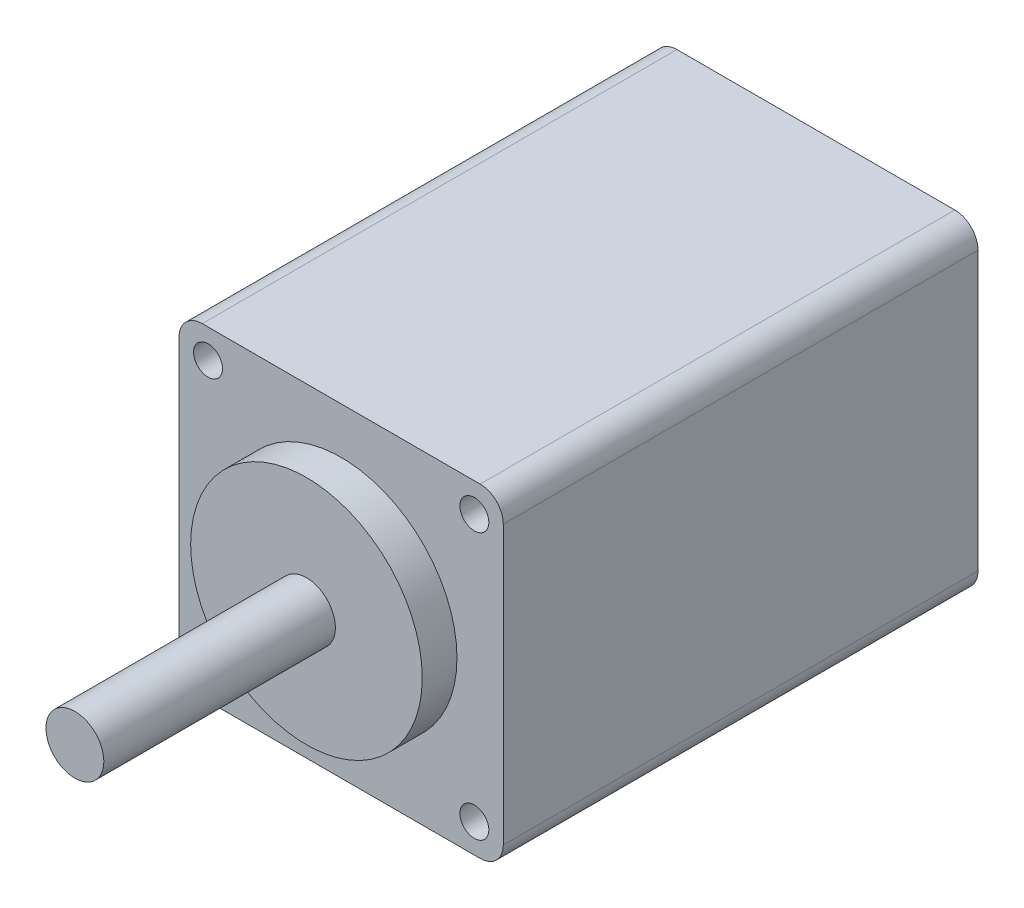
from build123d import *

# Parameters (mm, degrees)
SKETCH_1_W      = 28
SKETCH_1_H      = 28
SKETCH_1_R      = 1.25
EXTRUDE_1_DEPTH = 41
SKETCH_2_R      = 10
EXTRUDE_2_DEPTH = 3
SKETCH_3_R      = 2.5
EXTRUDE_3_DEPTH = 20
FILLET_1_R      = 2


with BuildPart() as part:
    # 草图1 → 凸台-拉伸1 (new body)
    with BuildSketch(Plane.XY):
        Rectangle(SKETCH_1_W, SKETCH_1_H)
        with Locations((-11.5, 11.5)):
            Circle(SKETCH_1_R, mode=Mode.SUBTRACT)
        with Locations((11.5, 11.5)):
            Circle(SKETCH_1_R, mode=Mode.SUBTRACT)
        with Locations((11.5, -11.5)):
            Circle(SKETCH_1_R, mode=Mode.SUBTRACT)
        with Locations((-11.5, -11.5)):
            Circle(SKETCH_1_R, mode=Mode.SUBTRACT)
    extrude(amount=EXTRUDE_1_DEPTH)

    # 草图2 → 凸台-拉伸2 (add)
    with BuildSketch(Plane.XY.offset(41)):
        Circle(SKETCH_2_R)
    extrude(amount=EXTRUDE_2_DEPTH)

    # 草图3 → 凸台-拉伸3 (add)
    with BuildSketch(Plane.XY.offset(44)):
        Circle(SKETCH_3_R)
    extrude(amount=EXTRUDE_3_DEPTH)

    # 圆角1
    fillet_1_edges = [part.edges().sort_by_distance(p)[0] for p in [
        (14, -14, 20.5),
        (-14, -14, 20.5),
        (-14, 14, 20.5),
        (14, 14, 20.5),
    ]]
    fillet(fillet_1_edges, radius=FILLET_1_R)


solid = part.part
